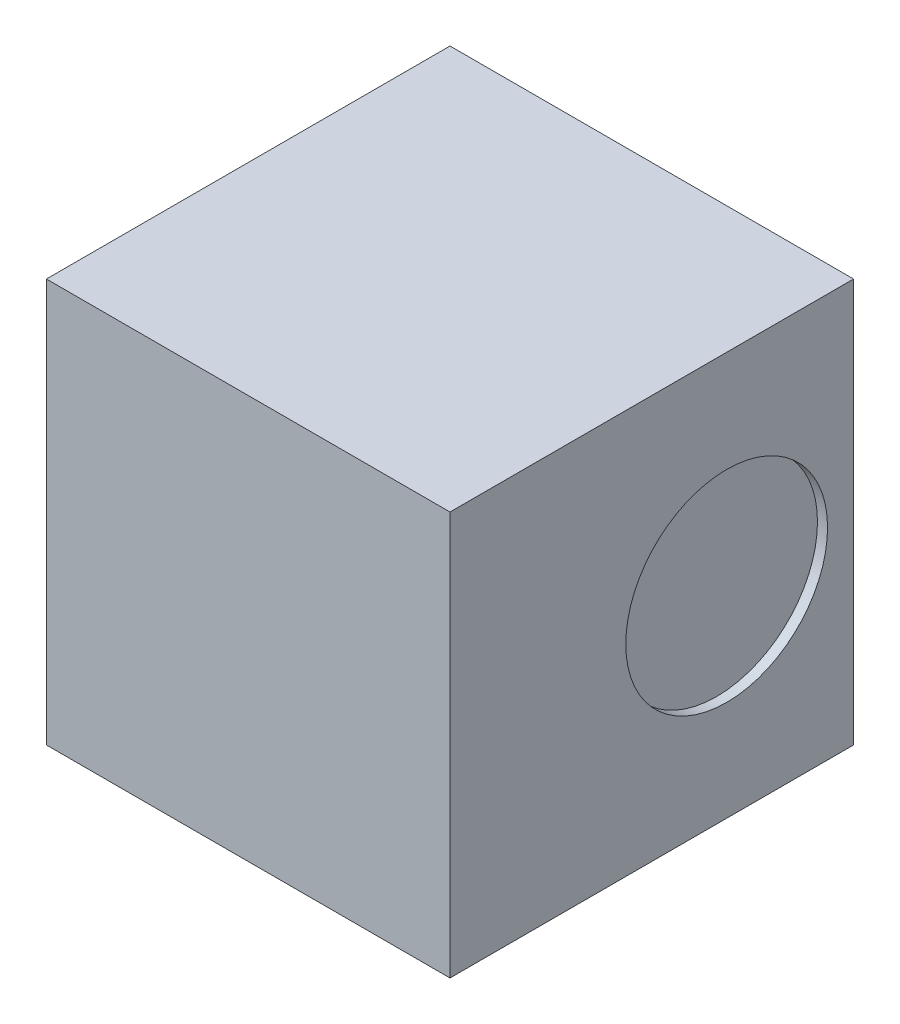
from build123d import *

# Parameters (mm, degrees)
SKETCH1_W           = 2
SKETCH1_H           = 2
BOSS_EXTRUDE1_DEPTH = 2
SKETCH2_R           = 0.5
CUT_EXTRUDE1_DEPTH  = 0.05


with BuildPart() as part:
    # Sketch1 → Boss-Extrude1 (new body)
    with BuildSketch(Plane(origin=(0, 0, 0), x_dir=(1, 0, 0), z_dir=(0, 1, 0))):
        Rectangle(SKETCH1_W, SKETCH1_H)
    extrude(amount=BOSS_EXTRUDE1_DEPTH)

    # Sketch2 → Cut-Extrude1 (cut)
    with BuildSketch(Plane(origin=(1, 0, 0), x_dir=(0, 0, -1), z_dir=(1, 0, 0))):
        with Locations((0.371123836, 0.997145201)):
            Circle(SKETCH2_R)
    extrude(amount=-CUT_EXTRUDE1_DEPTH, mode=Mode.SUBTRACT)


solid = part.part
